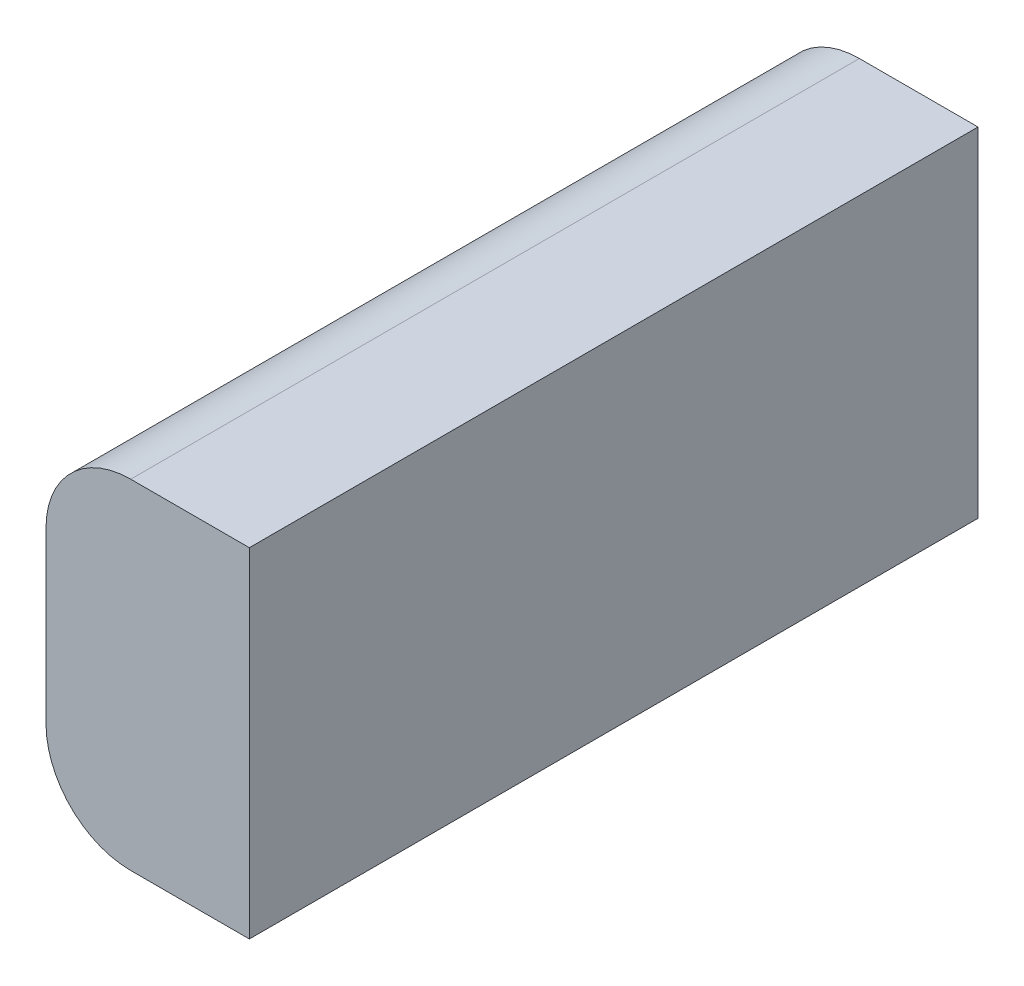
from build123d import *

# Parameters (mm, degrees)
SKETCH1_W           = 76.2
SKETCH1_H           = 127
BOSS_EXTRUDE1_DEPTH = 273.05
FILLET1_R           = 31.75


with BuildPart() as part:
    # Sketch1 → Boss-Extrude1 (new body)
    with BuildSketch(Plane.XY):
        with Locations((35.57989844, 47.54679803)):
            Rectangle(SKETCH1_W, SKETCH1_H)
    extrude(amount=BOSS_EXTRUDE1_DEPTH)

    # Fillet1
    fillet1_edges = [part.edges().sort_by_distance(p)[0] for p in [
        (-2.52010156, 111.04679803, 136.525),
        (-2.52010156, -15.95320197, 136.525),
    ]]
    fillet(fillet1_edges, radius=FILLET1_R)


solid = part.part
